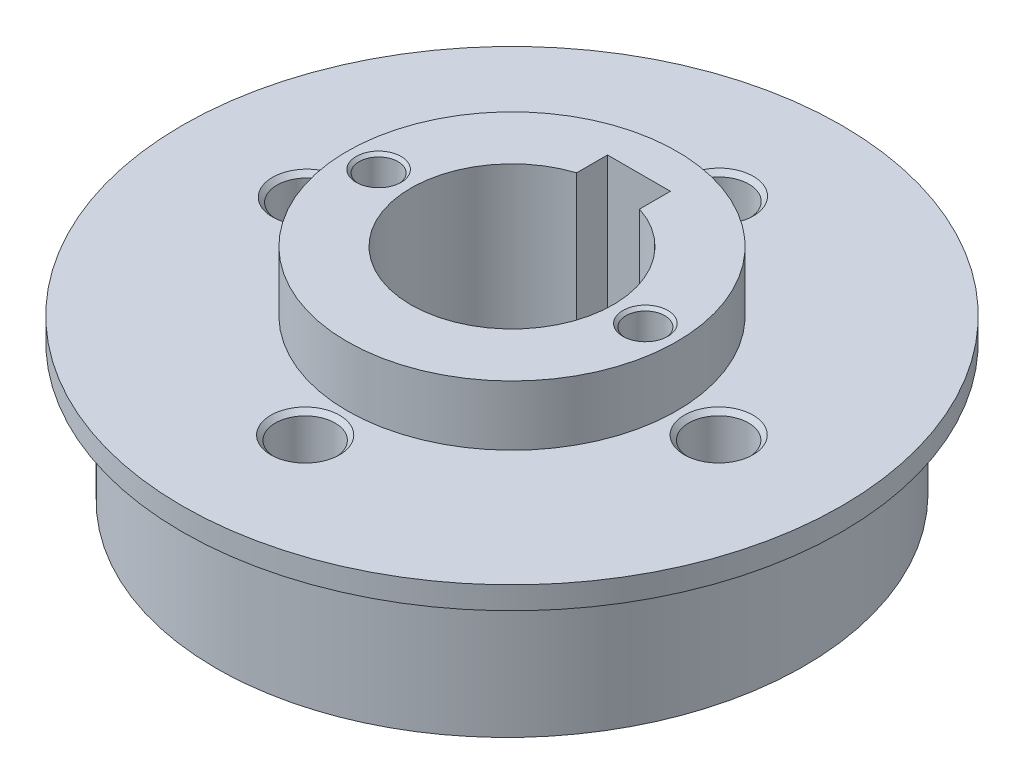
from build123d import *

# Parameters (mm, degrees)
SKETCH_1_R          = 22
EXTRUDE_1_DEPTH     = 18.5
SKETCH_2_R          = 22
SKETCH_2_R_2        = 11
CUT_EXTRUDE_1_DEPTH = 4
SKETCH_4_R          = 22
SKETCH_4_RX         = 19.75
SKETCH_4_RY         = 19.5
CUT_EXTRUDE_2_DEPTH = 13
SKETCH_5_R          = 21.651989758
SKETCH_5_R_2        = 11
CUT_EXTRUDE_3_DEPTH = 4
CUT_EXTRUDE_4_DEPTH = 19.5
HOLE_WIZARD_1_1_D   = 3.9878
SKETCH_33_R         = 1.3
CUT_EXTRUDE_5_DEPTH = 2.5
CHAMFER_1_SIZE      = 0.3
CHAMFER_2_SIZE      = 0.2


with BuildPart() as part:
    # 草图1 → 凸台-拉伸1 (new body)
    with BuildSketch(Plane(origin=(0, 0, 0), x_dir=(1, 0, 0), z_dir=(0, 1, 0))):
        Circle(SKETCH_1_R)
    extrude(amount=EXTRUDE_1_DEPTH)

    # 草图2 → 切除-拉伸1 (cut)
    with BuildSketch(Plane(origin=(0, 18.5, 0), x_dir=(1, 0, 0), z_dir=(0, 1, 0))):
        Circle(SKETCH_2_R)
        Circle(SKETCH_2_R_2, mode=Mode.SUBTRACT)
    extrude(amount=-CUT_EXTRUDE_1_DEPTH, mode=Mode.SUBTRACT)

    # 草图4 → 切除-拉伸2 (cut)
    with BuildSketch(Plane.XZ):
        Circle(SKETCH_4_R)
        with Locations(Location((0, 0), (0, 0, 90))):
            Ellipse(SKETCH_4_RX, SKETCH_4_RY, mode=Mode.SUBTRACT)
    extrude(amount=-CUT_EXTRUDE_2_DEPTH, mode=Mode.SUBTRACT)

    # 草图5 → 切除-拉伸3 (cut)
    with BuildSketch(Plane.XZ):
        Circle(SKETCH_5_R)
        Circle(SKETCH_5_R_2, mode=Mode.SUBTRACT)
    extrude(amount=-CUT_EXTRUDE_3_DEPTH, mode=Mode.SUBTRACT)

    # 草图6 → 切除-拉伸4 (cut, through all)
    with BuildSketch(Plane(origin=(0, 18.5, 0), x_dir=(1, 0, 0), z_dir=(0, 1, 0))):
        with BuildLine():
            Line((-2.097599684, 8.471245207), (2.097599684, 8.471245207))
            Line((2.097599684, 8.471245207), (2.097599684, 6.415806697))
            ThreePointArc((2.097599684, 6.415806697), (0, -6.75), (-2.097599684, 6.415806697))
            Line((-2.097599684, 6.415806697), (-2.097599684, 8.471245207))
        make_face()
    extrude(amount=-CUT_EXTRUDE_4_DEPTH, mode=Mode.SUBTRACT)

    # #1 螺旋的螺纹孔钻头1 (through all)
    with Locations(Plane(origin=(0, 14.5, 0), x_dir=(1, 0, 0), z_dir=(0, 1, 0))):
        with Locations((0, 13.810288315), (-85.484743378, -69.881752856), (13.789919005, 0), (0, -13.801039256), (-13.69075507, 0)):
            Hole(HOLE_WIZARD_1_1_D / 2)

    # 草图33 → 切除-拉伸5 (cut)
    with BuildSketch(Plane(origin=(0, 18.5, 0), x_dir=(1, 0, 0), z_dir=(0, 1, 0))):
        with Locations((8.9, 0)):
            Circle(SKETCH_33_R)
        with Locations((-8.9, 0)):
            Circle(SKETCH_33_R)
    extrude(amount=-CUT_EXTRUDE_5_DEPTH, mode=Mode.SUBTRACT)

    # 倒角1
    chamfer_1_edges = [part.edges().sort_by_distance(p)[0] for p in [
        (-11.69685507, 4, 0),
        (-11.69685507, 14.5, 0),
        (1.9939, 4, 13.801039256),
        (1.9939, 14.5, 13.801039256),
        (15.783819005, 4, 0),
        (15.783819005, 14.5, 0),
        (1.9939, 4, -13.810288315),
        (1.9939, 14.5, -13.810288315),
    ]]
    chamfer(chamfer_1_edges, length=CHAMFER_1_SIZE)

    # 倒角2
    chamfer_2_edges = [part.edges().sort_by_distance(p)[0] for p in [
        (7.6, 18.5, 0),
        (-10.2, 18.5, 0),
    ]]
    chamfer(chamfer_2_edges, length=CHAMFER_2_SIZE)


solid = part.part
